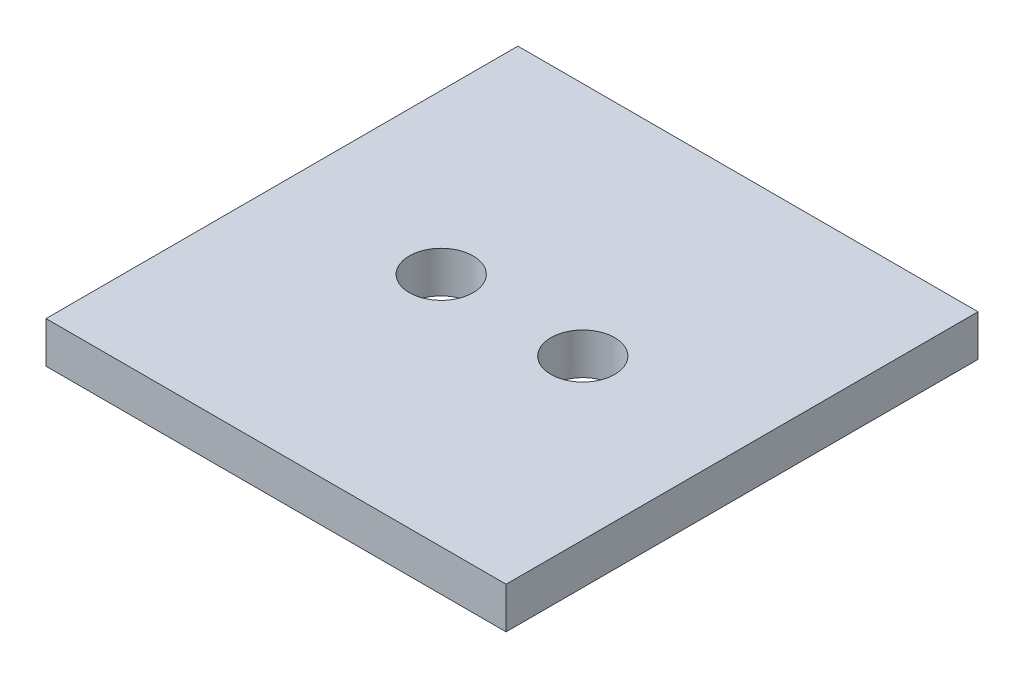
from build123d import *

# Parameters (mm, degrees)
SKETCH1_W                     = 19.5
SKETCH1_H                     = 20
BOSS_EXTRUDE1_DEPTH           = 1.75
TAP_DRILL_FOR_6_32_TAP1_D     = 2.7051
TAP_DRILL_FOR_6_32_TAP1_DEPTH = 10
TAP_DRILL_FOR_6_32_TAP1_TIP   = 0.81269403


with BuildPart() as part:
    # Sketch1 → Boss-Extrude1 (new body)
    with BuildSketch(Plane(origin=(0, 0, 0), x_dir=(1, 0, 0), z_dir=(0, 1, 0))):
        Rectangle(SKETCH1_W, SKETCH1_H)
    extrude(amount=BOSS_EXTRUDE1_DEPTH)

    # Tap Drill for #6-32 Tap1
    with Locations(Plane(origin=(0, 1.75, 0), x_dir=(1, 0, 0), z_dir=(0, 1, 0))):
        with Locations((3, 0), (-3, 0)):
            Hole(TAP_DRILL_FOR_6_32_TAP1_D / 2, depth=TAP_DRILL_FOR_6_32_TAP1_DEPTH)
            with Locations((0, 0, -(TAP_DRILL_FOR_6_32_TAP1_DEPTH + TAP_DRILL_FOR_6_32_TAP1_TIP / 2))):  # 118° drill point
                Cone(0, TAP_DRILL_FOR_6_32_TAP1_D / 2, TAP_DRILL_FOR_6_32_TAP1_TIP, mode=Mode.SUBTRACT)


solid = part.part
